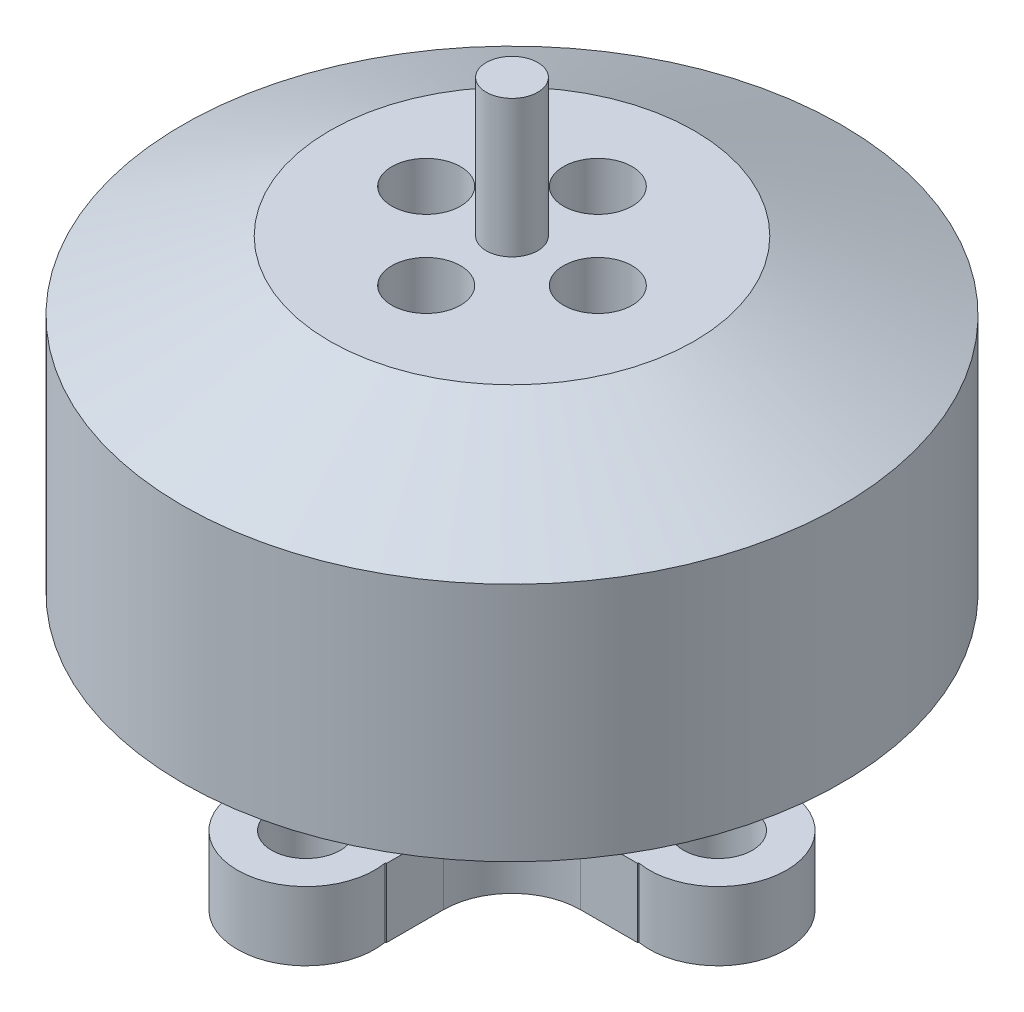
from build123d import *

# Parameters (mm, degrees)
SKETCH1_R           = 2
SKETCH1_R_2         = 1
BOSS_EXTRUDE1_DEPTH = 2
FILLET1_R           = 2
SKETCH2_R           = 3
BOSS_EXTRUDE2_DEPTH = 3
SKETCH3_R           = 9.6
BOSS_EXTRUDE3_DEPTH = 9
SKETCH4_R           = 0.75
BOSS_EXTRUDE4_DEPTH = 4
SKETCH5_R           = 1
CUT_EXTRUDE1_DEPTH  = 4
CHAMFER1_SIZE       = 2
CHAMFER1_SIZE2      = 4.289013841
CUT_EXTRUDE2_REACH  = 20.797
SKETCH6_R           = 8.1
SKETCH6_R_2         = 7.6


with BuildPart() as part:
    # Sketch1 → Boss-Extrude1 (new body)
    with BuildSketch(Plane(origin=(0, 0, 0), x_dir=(1, 0, 0), z_dir=(0, 1, 0))):
        with BuildLine():
            Line((-5.656854249, -2), (-2, -2))
            Line((-2, -2), (-2, -5.656854249))
            ThreePointArc((-2, -5.656854249), (-1.986019357, -5.661777734), (-1.972026594, -5.666666667))
            ThreePointArc((-1.972026594, -5.666666667), (0, -8), (1.972026594, -5.666666667))
            ThreePointArc((1.972026594, -5.666666667), (1.986019357, -5.661777734), (2, -5.656854249))
            Line((2, -5.656854249), (2, -2))
            Line((2, -2), (5.656854249, -2))
            ThreePointArc((5.656854249, -2), (5.661777734, -1.986019357), (5.666666667, -1.972026594))
            ThreePointArc((5.666666667, -1.972026594), (8, 0), (5.666666667, 1.972026594))
            ThreePointArc((5.666666667, 1.972026594), (5.661777734, 1.986019357), (5.656854249, 2))
            Line((5.656854249, 2), (2, 2))
            Line((2, 2), (2, 5.656854249))
            ThreePointArc((2, 5.656854249), (1.986019357, 5.661777734), (1.972026594, 5.666666667))
            ThreePointArc((1.972026594, 5.666666667), (0, 8), (-1.972026594, 5.666666667))
            ThreePointArc((-1.972026594, 5.666666667), (-1.986019357, 5.661777734), (-2, 5.656854249))
            Line((-2, 5.656854249), (-2, 2))
            Line((-2, 2), (-5.656854249, 2))
            ThreePointArc((-5.656854249, 2), (-5.661777734, 1.986019357), (-5.666666667, 1.972026594))
            ThreePointArc((-5.666666667, 1.972026594), (-8, 0), (-5.666666667, -1.972026594))
            ThreePointArc((-5.666666667, -1.972026594), (-5.661777734, -1.986019357), (-5.656854249, -2))
        make_face()
        with Locations(Location((0, 0, 0), (0, 0, 270))):
            Circle(SKETCH1_R, mode=Mode.SUBTRACT)
        with Locations(Location((6, 0, 0), (0, 0, 270))):
            Circle(SKETCH1_R_2, mode=Mode.SUBTRACT)
        with Locations(Location((0, 6, 0), (0, 0, 270))):
            Circle(SKETCH1_R_2, mode=Mode.SUBTRACT)
        with Locations(Location((-6, 0, 0), (0, 0, 270))):
            Circle(SKETCH1_R_2, mode=Mode.SUBTRACT)
        with Locations(Location((0, -6, 0), (0, 0, 270))):
            Circle(SKETCH1_R_2, mode=Mode.SUBTRACT)
    extrude(amount=BOSS_EXTRUDE1_DEPTH)

    # Fillet1
    fillet1_edges = [part.edges().sort_by_distance(p)[0] for p in [
        (2, 1, 2),
        (-2, 1, 2),
        (-2, 1, -2),
        (2, 1, -2),
    ]]
    fillet(fillet1_edges, radius=FILLET1_R)

    # Sketch2 → Boss-Extrude2 (add)
    with BuildSketch(Plane(origin=(0, 2, 0), x_dir=(1, 0, 0), z_dir=(0, 1, 0))):
        with Locations(Location((0, 0, 0), (0, 0, 270))):
            Circle(SKETCH2_R)
    extrude(amount=BOSS_EXTRUDE2_DEPTH)

    # Sketch3 → Boss-Extrude3 (add)
    with BuildSketch(Plane(origin=(0, 5, 0), x_dir=(1, 0, 0), z_dir=(0, 1, 0))):
        with Locations(Location((0, 0, 0), (0, 0, 270))):
            Circle(SKETCH3_R)
    extrude(amount=BOSS_EXTRUDE3_DEPTH)

    # Sketch4 → Boss-Extrude4 (add)
    with BuildSketch(Plane(origin=(0, 14, 0), x_dir=(1, 0, 0), z_dir=(0, 1, 0))):
        with Locations(Location((0, 0, 0), (0, 0, 270))):
            Circle(SKETCH4_R)
    extrude(amount=BOSS_EXTRUDE4_DEPTH)

    # Sketch5 → Cut-Extrude1 (cut)
    with BuildSketch(Plane(origin=(0, 14, 0), x_dir=(1, 0, 0), z_dir=(0, 1, 0))):
        with Locations(Location((-2.5, 0, 0), (0, 0, 270))):
            Circle(SKETCH5_R)
        with Locations(Location((0, 2.5, 0), (0, 0, 270))):
            Circle(SKETCH5_R)
        with Locations(Location((2.5, 0, 0), (0, 0, 270))):
            Circle(SKETCH5_R)
        with Locations(Location((0, -2.5, 0), (0, 0, 270))):
            Circle(SKETCH5_R)
    extrude(amount=-CUT_EXTRUDE1_DEPTH, mode=Mode.SUBTRACT)

    # Chamfer1
    chamfer1_edges = [part.edges().sort_by_distance(p)[0] for p in [
        (0, 14, -9.6),
    ]]
    chamfer1_side = [part.faces().sort_by_distance(p)[0] for p in [
        (0, 9.5, -9.6),
    ]]
    chamfer(chamfer1_edges, length=CHAMFER1_SIZE, length2=CHAMFER1_SIZE2, reference=chamfer1_side[0])

    # Cut-Extrude2: up to this cone (the profile starts inside it)
    cut_extrude2_end = Plane(origin=(0, 5, 0), z_dir=(0, -1, 0)).offset(-9.82148564) * Cone(2.145e-06, 111.901942411, 52.180731709, align=(Align.CENTER, Align.CENTER, Align.MIN), mode=Mode.PRIVATE)
    # Sketch6 → Cut-Extrude2 (cut, up to the surface)
    with BuildSketch(Plane.XZ.offset(-5), mode=Mode.PRIVATE) as cut_extrude2_sk1:
        with Locations(Location((0, 0, 0), (0, 0, 270))):
            Circle(SKETCH6_R)
        with Locations(Location((0, 0, 0), (0, 0, 270))):
            Circle(SKETCH6_R_2, mode=Mode.SUBTRACT)
    cut_extrude2_tool1 = extrude(cut_extrude2_sk1.sketch, amount=-CUT_EXTRUDE2_REACH, mode=Mode.PRIVATE) & cut_extrude2_end
    add(cut_extrude2_tool1.solids().sort_by_distance((0, 5, 7.870897))[0], mode=Mode.SUBTRACT)


solid = part.part
